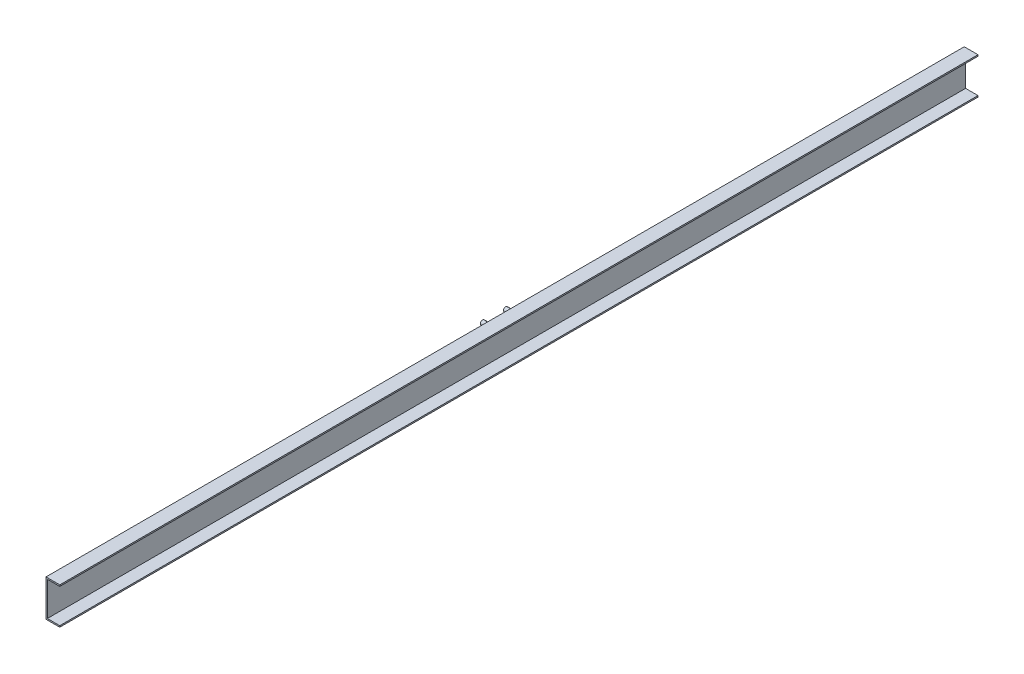
from build123d import *

# Parameters (mm, degrees)
SALIENTE_EXTRUIR1_DEPTH = 3500
CROQUIS2_R              = 4.85898955
SALIENTE_EXTRUIR2_DEPTH = 24
CROQUIS3_W              = 61.744916595
CROQUIS3_H              = 103.748261218
CORTAR_EXTRUIR1_DEPTH   = 750
CROQUIS4_W              = 41.753180027
CROQUIS4_H              = 90.106519095
CORTAR_EXTRUIR2_DEPTH   = 750


with BuildPart() as part:
    # Croquis1 → Saliente-Extruir1 (new body)
    with BuildSketch(Plane.XY):
        Polygon((0, 0), (0, 80), (30, 80), (30, 77), (3, 77), (3, 3), (30, 3), (30, 0), align=None)
    extrude(amount=SALIENTE_EXTRUIR1_DEPTH)

    # Croquis2 → Saliente-Extruir2 (add)
    with BuildSketch(Plane(origin=(0, 0, 0), x_dir=(0, 0, -1), z_dir=(1, 0, 0))):
        with Locations((-1725, 20.15133135)):
            Circle(CROQUIS2_R)
        with Locations((-1725, 60.453994049)):
            Circle(CROQUIS2_R)
        with Locations((-1775, 20.15133135)):
            Circle(CROQUIS2_R)
        with Locations((-1775, 60.453994049)):
            Circle(CROQUIS2_R)
    extrude(amount=-SALIENTE_EXTRUIR2_DEPTH)

    # Croquis3 → Cortar-Extruir1 (cut)
    with BuildSketch(Plane.XY):
        with Locations((6.570284293, 36.219698984)):
            Rectangle(CROQUIS3_W, CROQUIS3_H)
    extrude(amount=CORTAR_EXTRUIR1_DEPTH, mode=Mode.SUBTRACT)

    # Croquis4 → Cortar-Extruir2 (cut)
    with BuildSketch(Plane.XY.offset(3500)):
        with Locations((13.937202, 38.995627971)):
            Rectangle(CROQUIS4_W, CROQUIS4_H)
    extrude(amount=-CORTAR_EXTRUIR2_DEPTH, mode=Mode.SUBTRACT)


solid = part.part
